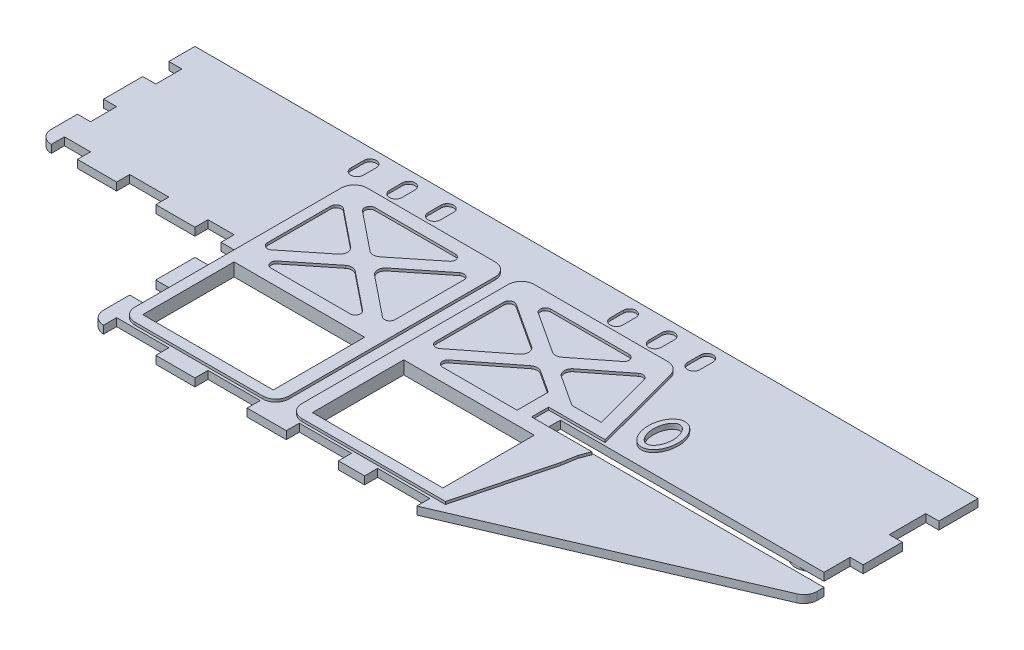
from build123d import *

# Parameters (mm, degrees)
SKETCH1_W           = 381
SKETCH1_H           = 6.35
BOSS_EXTRUDE1_DEPTH = 139.7
CUT_EXTRUDE1_DEPTH  = 7.35
SKETCH3_W           = 63.5
SKETCH3_H           = 44.45
CUT_EXTRUDE2_DEPTH  = 7.35
CUT_EXTRUDE3_DEPTH  = 1.27
CUT_EXTRUDE4_DEPTH  = 1.27
CUT_EXTRUDE5_DEPTH  = 1.27
SKETCH7_RX          = 10.638157658
SKETCH7_RY          = 7.265083279
BOSS_EXTRUDE2_DEPTH = 1.27
CUT_EXTRUDE6_DEPTH  = 2.54
SKETCH9_R           = 7.62
BOSS_EXTRUDE3_DEPTH = 1.27
SKETCH10_R          = 5.08
CUT_EXTRUDE7_DEPTH  = 2.54
SKETCH14_R          = 5.08
SKETCH14_W          = 11.43
SKETCH14_H          = 6.35
BOSS_EXTRUDE4_DEPTH = 1.27
SKETCH16_W          = 6.35
SKETCH16_H          = 12.7
CUT_EXTRUDE11_DEPTH = 6.35
SKETCH17_W          = 12.7
SKETCH17_H          = 6.35
SKETCH17_W_2        = 19.05
SKETCH17_W_3        = 6.35
SKETCH17_H_2        = 12.7
SKETCH17_W_4        = 25.4
SKETCH17_H_3        = 6.356953954
CUT_EXTRUDE12_DEPTH = 6.35
SKETCH18_W          = 6.35
SKETCH18_H          = 17.78
SKETCH18_H_2        = 19.05
CUT_EXTRUDE13_DEPTH = 6.35
SKETCH19_W          = 128.27
SKETCH19_H          = 6.35
CUT_EXTRUDE14_DEPTH = 6.35


with BuildPart() as part:
    # Sketch1 → Boss-Extrude1 (new body)
    with BuildSketch(Plane.XY):
        with Locations((-190.5, 3.175)):
            Rectangle(SKETCH1_W, SKETCH1_H)
    extrude(amount=BOSS_EXTRUDE1_DEPTH)

    # Sketch2 → Cut-Extrude1 (cut, through all)
    with BuildSketch(Plane.XZ):
        with BuildLine():
            ThreePointArc((-381, 69.85), (-379.140128061, 74.340128061), (-374.65, 76.2))
            Line((-374.65, 76.2), (-292.1, 76.2))
            Line((-292.1, 76.2), (-292.1, 133.35))
            ThreePointArc((-292.1, 133.35), (-290.240128061, 137.840128061), (-285.75, 139.7))
            Line((-285.75, 139.7), (-381, 139.7))
            Line((-381, 139.7), (-381, 69.85))
        make_face()
        with BuildLine():
            Line((0, 139.7), (-133.35, 139.7))
            Line((-133.35, 139.7), (-3.848612454, 84.199405337))
            ThreePointArc((-3.848612454, 84.199405337), (-1.048759064, 81.858452302), (0, 78.362834397))
            Line((0, 78.362834397), (0, 139.7))
        make_face()
    extrude(amount=-CUT_EXTRUDE1_DEPTH, mode=Mode.SUBTRACT)

    # Sketch3 → Cut-Extrude2 (cut, through all)
    with BuildSketch(Plane(origin=(0, 6.35, 0), x_dir=(1, 0, 0), z_dir=(0, 1, 0))):
        with Locations((-165.1, -104.775)):
            Rectangle(SKETCH3_W, SKETCH3_H)
        with Locations((-247.65, -104.775)):
            Rectangle(SKETCH3_W, SKETCH3_H)
    extrude(amount=-CUT_EXTRUDE2_DEPTH, mode=Mode.SUBTRACT)

    # Sketch4 → Cut-Extrude3 (cut)
    with BuildSketch(Plane.XZ):
        with BuildLine():
            Line((-3.848612454, 84.199405337), (-133.35, 139.7))
            Line((-133.35, 139.7), (-285.75, 139.7))
            ThreePointArc((-285.75, 139.7), (-290.240128061, 137.840128061), (-292.1, 133.35))
            Line((-292.1, 133.35), (-292.1, 76.2))
            Line((-292.1, 76.2), (-374.65, 76.2))
            ThreePointArc((-374.65, 76.2), (-379.140128061, 74.340128061), (-381, 69.85))
            Line((-381, 69.85), (-381, 0))
            Line((-381, 0), (0, 0))
            Line((0, 0), (0, 78.362834397))
            ThreePointArc((0, 78.362834397), (-1.048759064, 81.858452302), (-3.848612454, 84.199405337))
        make_face()
        with BuildLine():
            ThreePointArc((-284.48, 125.73), (-282.620128061, 130.220128061), (-278.13, 132.08))
            Line((-278.13, 132.08), (-215.9, 132.08))
            ThreePointArc((-215.9, 132.08), (-211.409871939, 130.220128061), (-209.55, 125.73))
            Line((-209.55, 125.73), (-209.55, 25.4))
            ThreePointArc((-209.55, 25.4), (-211.409871939, 20.909871939), (-215.9, 19.05))
            Line((-215.9, 19.05), (-278.13, 19.05))
            ThreePointArc((-278.13, 19.05), (-282.620128061, 20.909871939), (-284.48, 25.4))
            Line((-284.48, 25.4), (-284.48, 125.73))
        make_face(mode=Mode.SUBTRACT)
        with BuildLine():
            Line((-196.85, 132.08), (-127, 132.08))
            Line((-127, 132.08), (-115.477155753, 87.731961905))
            Line((-115.477155753, 87.731961905), (-114.183529148, 80.322144423))
            Line((-114.183529148, 80.322144423), (-112.331369942, 75.513693666))
            Line((-112.331369942, 75.513693666), (-141.716346789, 75.513693666))
            Line((-141.716346789, 75.513693666), (-141.716346789, 67.193512479))
            Line((-141.716346789, 67.193512479), (-114.183529148, 67.193512479))
            Line((-114.183529148, 67.193512479), (-125.744419224, 23.76643633))
            ThreePointArc((-125.744419224, 23.76643633), (-128.010988421, 20.365338676), (-131.88070228, 19.05))
            Line((-131.88070228, 19.05), (-196.85, 19.05))
            ThreePointArc((-196.85, 19.05), (-201.340128061, 20.909871939), (-203.2, 25.4))
            Line((-203.2, 25.4), (-203.2, 125.73))
            ThreePointArc((-203.2, 125.73), (-201.340128061, 130.220128061), (-196.85, 132.08))
        make_face(mode=Mode.SUBTRACT)
    cut_extrude3 = extrude(amount=-CUT_EXTRUDE3_DEPTH, mode=Mode.SUBTRACT)

    # Sketch5 → Cut-Extrude4 (cut)
    with BuildSketch(Plane.XZ):
        with BuildLine():
            Line((-269.314924816, 71.676593224), (-250.861622366, 56.913951264))
            ThreePointArc((-250.861622366, 56.913951264), (-248.477387972, 56.079063684), (-246.09497637, 56.919138608))
            Line((-246.09497637, 56.919138608), (-227.725938458, 71.680051453))
            ThreePointArc((-227.725938458, 71.680051453), (-226.921077485, 74.503365488), (-229.316977035, 76.2))
            Line((-229.316977035, 76.2), (-267.728199395, 76.2))
            ThreePointArc((-267.728199395, 76.2), (-270.125015326, 74.500757631), (-269.314924816, 71.676593224))
        make_face()
        with BuildLine():
            ThreePointArc((-257.251499201, 47.954027754), (-255.828059322, 50.928096837), (-257.257968935, 53.899060738))
            Line((-257.257968935, 53.899060738), (-275.273274579, 68.311305253))
            ThreePointArc((-275.273274579, 68.311305253), (-277.960299375, 68.617208697), (-279.4, 66.327898477))
            Line((-279.4, 66.327898477), (-279.4, 35.455581143))
            ThreePointArc((-279.4, 35.455581143), (-277.957807364, 33.165074869), (-275.268961423, 33.475632597))
            Line((-275.268961423, 33.475632597), (-257.251499201, 47.954027754))
        make_face()
        with BuildLine():
            Line((-148.066346789, 76.2), (-184.323422249, 76.2))
            ThreePointArc((-184.323422249, 76.2), (-186.724879694, 74.487406876), (-185.887975323, 71.659056802))
            Line((-185.887975323, 71.659056802), (-163.421462968, 54.092315777))
            ThreePointArc((-163.421462968, 54.092315777), (-161.23709196, 53.287195771), (-158.992065813, 53.903274114))
            Line((-158.992065813, 53.903274114), (-148.066346789, 61.035027241))
            Line((-148.066346789, 61.035027241), (-148.066346789, 76.2))
        make_face()
        with BuildLine():
            Line((-122.445147598, 60.843512479), (-136.742593782, 60.843512479))
            Line((-136.742593782, 60.843512479), (-151.528786111, 51.191838923))
            ThreePointArc((-151.528786111, 51.191838923), (-153.252753369, 48.163841066), (-151.793048177, 44.999967667))
            Line((-151.793048177, 44.999967667), (-134.022318328, 31.104895564))
            ThreePointArc((-134.022318328, 31.104895564), (-131.650325923, 30.697594229), (-130.003252032, 32.452413293))
            Line((-130.003252032, 32.452413293), (-122.445147598, 60.843512479))
        make_face()
        with BuildLine():
            ThreePointArc((-192.745446926, 68.960268685), (-195.423021831, 69.242477345), (-196.85, 66.959325487))
            Line((-196.85, 66.959325487), (-196.85, 33.882758471))
            ThreePointArc((-196.85, 33.882758471), (-195.519363254, 31.649142452), (-192.921621637, 31.755787497))
            Line((-192.921621637, 31.755787497), (-171.352886828, 45.834759471))
            ThreePointArc((-171.352886828, 45.834759471), (-169.62891957, 48.862757328), (-171.088624762, 52.026630727))
            Line((-171.088624762, 52.026630727), (-192.745446926, 68.960268685))
        make_face()
        with BuildLine():
            Line((-182.503329952, 25.4), (-144.407280031, 25.4))
            ThreePointArc((-144.407280031, 25.4), (-142.005822585, 27.112593124), (-142.842726957, 29.940943198))
            Line((-142.842726957, 29.940943198), (-159.460209971, 42.934282617))
            ThreePointArc((-159.460209971, 42.934282617), (-161.644580979, 43.739402623), (-163.889607126, 43.123324281))
            Line((-163.889607126, 43.123324281), (-183.891708315, 30.066970973))
            ThreePointArc((-183.891708315, 30.066970973), (-184.937883944, 27.215743924), (-182.503329952, 25.4))
        make_face()
        with BuildLine():
            ThreePointArc((-228.875126903, 25.4), (-226.478310973, 27.099242369), (-227.288401483, 29.923406776))
            Line((-227.288401483, 29.923406776), (-246.081959833, 44.958253456))
            ThreePointArc((-246.081959833, 44.958253456), (-248.466194227, 45.793141036), (-250.848605829, 44.953066112))
            Line((-250.848605829, 44.953066112), (-269.556385584, 29.919948547))
            ThreePointArc((-269.556385584, 29.919948547), (-270.361246557, 27.096634512), (-267.965347007, 25.4))
            Line((-267.965347007, 25.4), (-228.875126903, 25.4))
        make_face()
        with BuildLine():
            Line((-239.685613264, 47.973143982), (-220.026725421, 32.246033708))
            ThreePointArc((-220.026725421, 32.246033708), (-217.339700625, 31.940130264), (-215.9, 34.229440484))
            Line((-215.9, 34.229440484), (-215.9, 67.737366324))
            ThreePointArc((-215.9, 67.737366324), (-217.342192636, 70.027872598), (-220.031038577, 69.71731487))
            Line((-220.031038577, 69.71731487), (-239.692082997, 53.918176966))
            ThreePointArc((-239.692082997, 53.918176966), (-241.115522876, 50.944107883), (-239.685613264, 47.973143982))
        make_face()
    cut_extrude4 = extrude(amount=-CUT_EXTRUDE4_DEPTH, mode=Mode.SUBTRACT)

    # Sketch6 → Cut-Extrude5 (cut)
    with BuildSketch(Plane.XZ.offset(-1.27)):
        with BuildLine():
            Line((-248.158, 6.985), (-248.158, 13.335))
            ThreePointArc((-248.158, 13.335), (-251.206, 16.383), (-254.254, 13.335))
            Line((-254.254, 13.335), (-254.254, 6.985))
            ThreePointArc((-254.254, 6.985), (-251.206, 3.937), (-248.158, 6.985))
        make_face()
        with BuildLine():
            Line((-159.512, 6.985), (-159.512, 13.335))
            ThreePointArc((-159.512, 13.335), (-162.56, 16.383), (-165.608, 13.335))
            Line((-165.608, 13.335), (-165.608, 6.985))
            ThreePointArc((-165.608, 6.985), (-162.56, 3.937), (-159.512, 6.985))
        make_face()
        with BuildLine():
            Line((-140.716, 6.985), (-140.716, 13.335))
            ThreePointArc((-140.716, 13.335), (-143.764, 16.383), (-146.812, 13.335))
            Line((-146.812, 13.335), (-146.812, 6.985))
            ThreePointArc((-146.812, 6.985), (-143.764, 3.937), (-140.716, 6.985))
        make_face()
        with BuildLine():
            Line((-121.92, 6.985), (-121.92, 13.335))
            ThreePointArc((-121.92, 13.335), (-124.968, 16.383), (-128.016, 13.335))
            Line((-128.016, 13.335), (-128.016, 6.985))
            ThreePointArc((-128.016, 6.985), (-124.968, 3.937), (-121.92, 6.985))
        make_face()
        with BuildLine():
            Line((-266.954, 6.985), (-266.954, 13.335))
            ThreePointArc((-266.954, 13.335), (-270.002, 16.383), (-273.05, 13.335))
            Line((-273.05, 13.335), (-273.05, 6.985))
            ThreePointArc((-273.05, 6.985), (-270.002, 3.937), (-266.954, 6.985))
        make_face()
        with BuildLine():
            Line((-285.75, 6.985), (-285.75, 13.335))
            ThreePointArc((-285.75, 13.335), (-288.798, 16.383), (-291.846, 13.335))
            Line((-291.846, 13.335), (-291.846, 6.985))
            ThreePointArc((-291.846, 6.985), (-288.798, 3.937), (-285.75, 6.985))
        make_face()
    cut_extrude5 = extrude(amount=-CUT_EXTRUDE5_DEPTH, mode=Mode.SUBTRACT)

    # Sketch7 → Boss-Extrude2 (add)
    with BuildSketch(Plane.XZ.offset(-1.27)):
        with Locations(Location((-102.329210388, 50.8), (0, 0, 90))):
            Ellipse(SKETCH7_RX, SKETCH7_RY)
    boss_extrude2 = extrude(amount=BOSS_EXTRUDE2_DEPTH)

    # Sketch8 → Cut-Extrude6 (cut)
    with BuildSketch(Plane.XZ):
        with BuildLine():
            add(Edge.make_bspline(
                [(-102.329210388, 42.701842342), (-102.112758869, 42.701842342), (-101.90165855, 42.730798568), (-101.488693819, 42.838688028), (-101.285989099, 42.918556352), (-100.906134378, 43.111892013), (-100.726271614, 43.225872461), (-100.382645705, 43.481527117), (-100.219893263, 43.622784261), (-99.764069992, 44.069079946), (-99.497769004, 44.39994929), (-99.020239481, 45.110543643), (-98.814571853, 45.482887589), (-98.456537688, 46.248561552), (-98.303821873, 46.642945525), (-98.043897216, 47.451692305), (-97.93694989, 47.86674898), (-97.685170772, 49.110986426), (-97.604474239, 49.948930056), (-97.603955181, 51.21753352), (-97.624537227, 51.64479256), (-97.707574037, 52.489514624), (-97.769697493, 52.906773584), (-98.019835892, 54.142760692), (-98.268534926, 54.94646269), (-98.81064993, 56.110152691), (-99.016899152, 56.483521228), (-99.490891269, 57.19076015), (-99.76140618, 57.527809822), (-100.216477408, 57.974118423), (-100.376714264, 58.113519663), (-100.718552192, 58.368903489), (-100.901455485, 58.485361462), (-101.281621707, 58.679577276), (-101.480360605, 58.758600286), (-101.897705612, 58.86868778), (-102.108175779, 58.897382796), (-102.532927978, 58.898901561), (-102.749721759, 58.870474195), (-103.163652722, 58.76344783), (-103.364910451, 58.684789272), (-103.747979792, 58.490767734), (-103.92786111, 58.376911798), (-104.269743776, 58.123354052), (-104.432452105, 57.982782611), (-104.892344941, 57.533629711), (-105.158068026, 57.203116225), (-105.632472982, 56.498716444), (-105.84141111, 56.121920037), (-106.381043429, 54.969101305), (-106.633833171, 54.162979986), (-106.88839125, 52.910018282), (-106.950841871, 52.488975534), (-107.033547657, 51.648795729), (-107.054050785, 51.228316152), (-107.054532282, 50.386599606), (-107.034513011, 49.96536268), (-106.952348017, 49.122101501), (-106.889682762, 48.698185433), (-106.637395321, 47.450926305), (-106.38643813, 46.644874219), (-105.845816734, 45.486290284), (-105.638318792, 45.11115305), (-105.283208535, 44.58212192), (-105.157215657, 44.410864931), (-104.887261102, 44.080341608), (-104.742776803, 43.920680923), (-104.438331426, 43.622585508), (-104.277847031, 43.483320984), (-103.936531746, 43.228885445), (-103.753864897, 43.112784869), (-103.373085917, 42.918800422), (-103.175006788, 42.840400135), (-102.759198786, 42.731108531), (-102.545661908, 42.701842342), (-102.329210388, 42.701842342)],
                knots=[0, 0, 0, 0, 0.015625, 0.015625, 0.03125, 0.03125, 0.046875, 0.046875, 0.0625, 0.0625, 0.09375, 0.09375, 0.125, 0.125, 0.15625, 0.15625, 0.1875, 0.1875, 0.25, 0.25, 0.28125, 0.28125, 0.3125, 0.3125, 0.375, 0.375, 0.40625, 0.40625, 0.4375, 0.4375, 0.453125, 0.453125, 0.46875, 0.46875, 0.484375, 0.484375, 0.5, 0.5, 0.515625, 0.515625, 0.53125, 0.53125, 0.546875, 0.546875, 0.5625, 0.5625, 0.59375, 0.59375, 0.625, 0.625, 0.6875, 0.6875, 0.71875, 0.71875, 0.75, 0.75, 0.78125, 0.78125, 0.8125, 0.8125, 0.875, 0.875, 0.90625, 0.90625, 0.921875, 0.921875, 0.9375, 0.9375, 0.953125, 0.953125, 0.96875, 0.96875, 0.984375, 0.984375, 1, 1, 1, 1], degree=3))
        make_face()
    cut_extrude6 = extrude(amount=-CUT_EXTRUDE6_DEPTH, mode=Mode.SUBTRACT)

    # Sketch9 → Boss-Extrude3 (add)
    with BuildSketch(Plane.XZ.offset(-1.27)):
        with Locations((-20.387686115, 60.831492086)):
            Circle(SKETCH9_R)
    extrude(amount=BOSS_EXTRUDE3_DEPTH)

    # Sketch10 → Cut-Extrude7 (cut)
    with BuildSketch(Plane.XZ):
        with Locations((-20.387686115, 60.831492086)):
            Circle(SKETCH10_R)
    extrude(amount=-CUT_EXTRUDE7_DEPTH, mode=Mode.SUBTRACT)

    # Sketch14 → Boss-Extrude4 (add)
    with BuildSketch(Plane.XZ.offset(-1.27)):
        with Locations((-370.84, 62.855298511)):
            Circle(SKETCH14_R)
        with Locations((-349.885, 69.692429512)):
            Rectangle(SKETCH14_W, SKETCH14_H)
    extrude(amount=BOSS_EXTRUDE4_DEPTH)

    # Mirror7: Cut-Extrude3 across plane
    add(cut_extrude3.mirror(Plane(origin=(0, 3.175, 0), x_dir=(0, 0, 1), z_dir=(0, -1, 0))), mode=Mode.SUBTRACT)

    # Mirror8: Cut-Extrude4, Cut-Extrude5, Boss-Extrude2, Cut-Extrude6 across plane
    add(cut_extrude4.mirror(Plane(origin=(0, 3.175, 0), x_dir=(0, 0, 1), z_dir=(0, -1, 0))), mode=Mode.SUBTRACT)
    add(cut_extrude5.mirror(Plane(origin=(0, 3.175, 0), x_dir=(0, 0, 1), z_dir=(0, -1, 0))), mode=Mode.SUBTRACT)
    add(boss_extrude2.mirror(Plane(origin=(0, 3.175, 0), x_dir=(0, 0, 1), z_dir=(0, -1, 0))))
    add(cut_extrude6.mirror(Plane(origin=(0, 3.175, 0), x_dir=(0, 0, 1), z_dir=(0, -1, 0))), mode=Mode.SUBTRACT)

    # Sketch16 → Cut-Extrude11 (cut)
    with BuildSketch(Plane(origin=(0, 5.08, 0), x_dir=(1, 0, 0), z_dir=(0, 1, 0))):
        with Locations((-377.825, -19.05)):
            Rectangle(SKETCH16_W, SKETCH16_H)
        with Locations((-377.825, -50.8)):
            Rectangle(SKETCH16_W, SKETCH16_H)
    extrude(amount=-CUT_EXTRUDE11_DEPTH, mode=Mode.SUBTRACT)

    # Sketch17 → Cut-Extrude12 (cut)
    with BuildSketch(Plane(origin=(0, 5.08, 0), x_dir=(1, 0, 0), z_dir=(0, 1, 0))):
        with Locations((-368.3, -73.025)):
            Rectangle(SKETCH17_W, SKETCH17_H)
        with Locations((-333.375, -73.025)):
            Rectangle(SKETCH17_W_2, SKETCH17_H)
        with Locations((-298.45, -73.025)):
            Rectangle(SKETCH17_W, SKETCH17_H)
        with Locations((-288.925, -82.55)):
            Rectangle(SKETCH17_W_3, SKETCH17_H_2)
        with Locations((-288.925, -114.3)):
            Rectangle(SKETCH17_W_3, SKETCH17_H_2)
        with Locations((-273.05, -136.525)):
            Rectangle(SKETCH17_W_4, SKETCH17_H)
        with Locations((-228.6, -136.525)):
            Rectangle(SKETCH17_W_4, SKETCH17_H)
        with Locations((-184.15, -136.528476977)):
            Rectangle(SKETCH17_W_4, SKETCH17_H_3)
        with Locations((-146.05, -136.525)):
            Rectangle(SKETCH17_W_4, SKETCH17_H)
    extrude(amount=-CUT_EXTRUDE12_DEPTH, mode=Mode.SUBTRACT)

    # Sketch18 → Cut-Extrude13 (cut)
    with BuildSketch(Plane(origin=(0, 5.08, 0), x_dir=(1, 0, 0), z_dir=(0, 1, 0))):
        with Locations((-3.175, -27.94)):
            Rectangle(SKETCH18_W, SKETCH18_H)
        with Locations((-3.175, -65.405)):
            Rectangle(SKETCH18_W, SKETCH18_H_2)
    extrude(amount=-CUT_EXTRUDE13_DEPTH, mode=Mode.SUBTRACT)

    # Sketch19 → Cut-Extrude14 (cut)
    with BuildSketch(Plane.XZ):
        with Locations((-70.485, 71.755)):
            Rectangle(SKETCH19_W, SKETCH19_H)
    extrude(amount=-CUT_EXTRUDE14_DEPTH, mode=Mode.SUBTRACT)


solid = part.part
